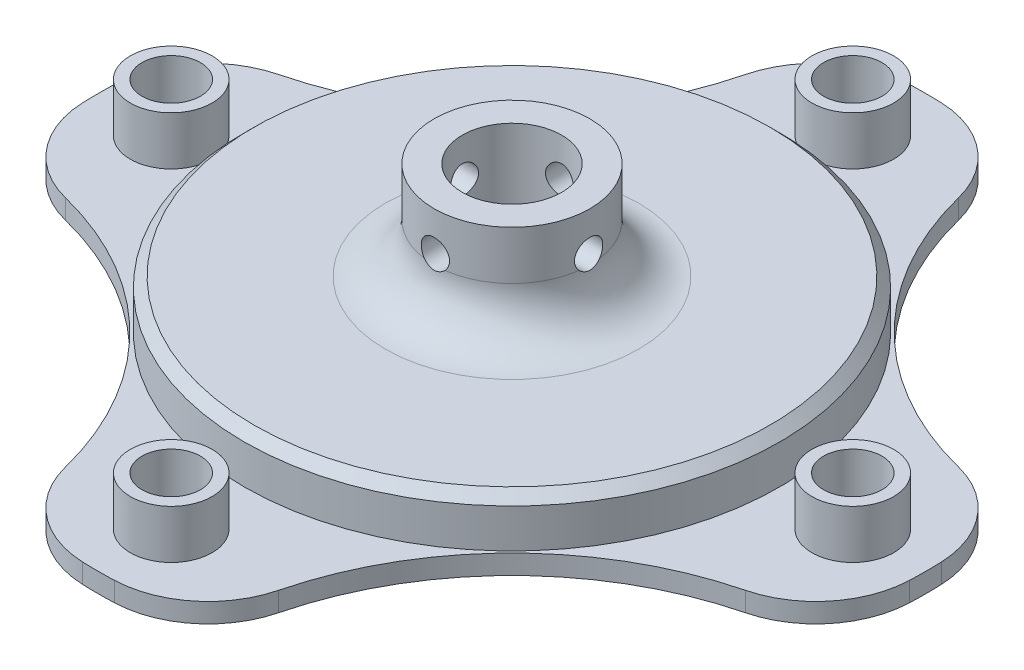
from build123d import *

# Parameters (mm, degrees)
SKETCH1_R           = 27.5
BOSS_EXTRUDE1_DEPTH = 5
SKETCH2_R           = 42.5
BOSS_EXTRUDE2_DEPTH = 2
SKETCH3_R           = 3
CUT_EXTRUDE1_DEPTH  = 2
FILLET1_R           = 10
SKETCH6_R           = 8
BOSS_EXTRUDE3_DEPTH = 10
FILLET2_R           = 5
SKETCH7_R           = 5.1
CUT_EXTRUDE4_DEPTH  = 20
SKETCH10_R          = 1.45
CUT_EXTRUDE5_DEPTH  = 43.5000001
CIRPATTERN1_COUNT   = 4
CHAMFER1_SIZE       = 1
SKETCH11_R          = 4.2
SKETCH11_R_2        = 3
BOSS_EXTRUDE4_DEPTH = 5


with BuildPart() as part:
    # Sketch1 → Boss-Extrude1 (new body)
    with BuildSketch(Plane(origin=(0, 0, 0), x_dir=(1, 0, 0), z_dir=(0, 1, 0))):
        Circle(SKETCH1_R)
    extrude(amount=-BOSS_EXTRUDE1_DEPTH)

    # Sketch2 → Boss-Extrude2 (add)
    with BuildSketch(Plane.XZ.offset(5)):
        Circle(SKETCH2_R)
    extrude(amount=BOSS_EXTRUDE2_DEPTH)

    # Sketch3 → Cut-Extrude1 (cut)
    with BuildSketch(Plane(origin=(0, -5, 0), x_dir=(1, 0, 0), z_dir=(0, 1, 0))):
        with BuildLine():
            ThreePointArc((-41.306779105, 10), (-19.624107624, 19.624107624), (-10, 41.306779105))
            ThreePointArc((-10, 41.306779105), (-30.0520382, 30.0520382), (-41.306779105, 10))
        make_face()
        with Locations((0, 35)):
            Circle(SKETCH3_R)
        with BuildLine():
            ThreePointArc((41.306779105, 10), (30.0520382, 30.0520382), (10, 41.306779105))
            ThreePointArc((10, 41.306779105), (19.624107624, 19.624107624), (41.306779105, 10))
        make_face()
        with Locations((35, 0)):
            Circle(SKETCH3_R)
        with Locations((0, -35)):
            Circle(SKETCH3_R)
        with BuildLine():
            ThreePointArc((41.306779105, -10), (19.624107624, -19.624107624), (10, -41.306779105))
            ThreePointArc((10, -41.306779105), (30.0520382, -30.0520382), (41.306779105, -10))
        make_face()
        with BuildLine():
            ThreePointArc((-10, -41.306779105), (-19.624107624, -19.624107624), (-41.306779105, -10))
            ThreePointArc((-41.306779105, -10), (-30.0520382, -30.0520382), (-10, -41.306779105))
        make_face()
        with Locations((-35, 0)):
            Circle(SKETCH3_R)
    extrude(amount=-CUT_EXTRUDE1_DEPTH, mode=Mode.SUBTRACT)

    # Fillet1
    fillet1_edges = [part.edges().sort_by_distance(p)[0] for p in [
        (41.306779105, -6, -10),
        (10, -6, -41.306779105),
        (10, -6, 41.306779105),
        (41.306779105, -6, 10),
        (-41.306779105, -6, 10),
        (-10, -6, 41.306779105),
        (-10, -6, -41.306779105),
        (-41.306779105, -6, -10),
    ]]
    fillet(fillet1_edges, radius=FILLET1_R)

    # Sketch6 → Boss-Extrude3 (add)
    with BuildSketch(Plane(origin=(0, 0, 0), x_dir=(1, 0, 0), z_dir=(0, 1, 0))):
        Circle(SKETCH6_R)
    extrude(amount=BOSS_EXTRUDE3_DEPTH)

    # Fillet2
    fillet2_edges = [part.edges().sort_by_distance(p)[0] for p in [
        (-8, 0, 0),
    ]]
    fillet(fillet2_edges, radius=FILLET2_R)

    # Sketch7 → Cut-Extrude4 (cut)
    with BuildSketch(Plane(origin=(0, 10, 0), x_dir=(1, 0, 0), z_dir=(0, 1, 0))):
        Circle(SKETCH7_R)
    extrude(amount=-CUT_EXTRUDE4_DEPTH, mode=Mode.SUBTRACT)

    # Sketch10 → Cut-Extrude5 (cut, symmetric)
    with BuildSketch(Plane.XY):
        with Locations((0, 6)):
            Circle(SKETCH10_R)
    cut_extrude5 = extrude(amount=CUT_EXTRUDE5_DEPTH, both=True, mode=Mode.SUBTRACT)

    # CirPattern1: Cut-Extrude5 ×4 about axis
    cirpattern1_axis = Axis((0, 10, 0), (0, -1, 0))
    for i in range(1, CIRPATTERN1_COUNT):
        add(cut_extrude5.rotate(cirpattern1_axis, i * 360 / CIRPATTERN1_COUNT), mode=Mode.SUBTRACT)

    # Chamfer1
    chamfer1_edges = [part.edges().sort_by_distance(p)[0] for p in [
        (-27.5, 0, 0),
    ]]
    chamfer(chamfer1_edges, length=CHAMFER1_SIZE)

    # Sketch11 → Boss-Extrude4 (add)
    with BuildSketch(Plane(origin=(0, -5, 0), x_dir=(1, 0, 0), z_dir=(0, 1, 0))):
        with Locations((0, -35)):
            Circle(SKETCH11_R)
        with Locations((0, -35)):
            Circle(SKETCH11_R_2, mode=Mode.SUBTRACT)
        with Locations((35, 0)):
            Circle(SKETCH11_R)
        with Locations((35, 0)):
            Circle(SKETCH11_R_2, mode=Mode.SUBTRACT)
        with Locations((0, 35)):
            Circle(SKETCH11_R)
        with Locations((0, 35)):
            Circle(SKETCH11_R_2, mode=Mode.SUBTRACT)
        with Locations((-35, 0)):
            Circle(SKETCH11_R)
        with Locations((-35, 0)):
            Circle(SKETCH11_R_2, mode=Mode.SUBTRACT)
    extrude(amount=BOSS_EXTRUDE4_DEPTH)


solid = part.part
